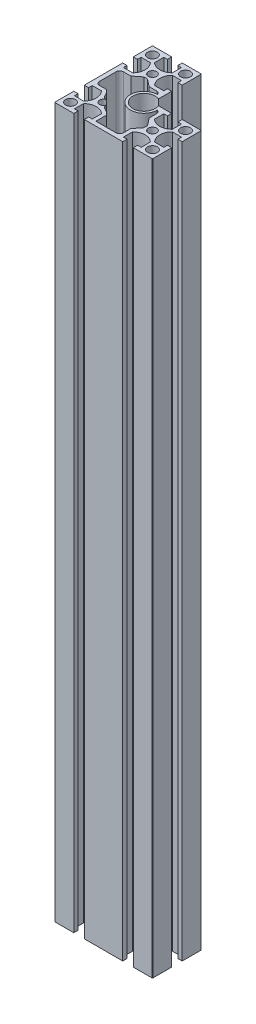
from build123d import *

# Parameters (mm, degrees)
SKETCH_2_R          = 4
SKETCH_2_R_2        = 3.4
EXTRUDE_1_DEPTH     = 580
SKETCH_3_R          = 5.341354258
SKETCH_3_R_2        = 5.383492222
SKETCH_3_R_3        = 4.933832051
SKETCH_3_R_4        = 5.418030405
SKETCH_3_R_5        = 5.574298651
EXTRUDE_2_DEPTH     = 580
SKETCH_4_R          = 4
CUT_EXTRUDE_1_DEPTH = 581


with BuildPart() as part:
    # 草图2 → 凸台-拉伸1 (new body)
    with BuildSketch(Plane(origin=(0, 0, 0), x_dir=(1, 0, 0), z_dir=(0, 1, 0))):
        with BuildLine():
            Line((212.330022346, 152.083698324), (201.421584322, 152.083698324))
            ThreePointArc((201.421584322, 152.083698324), (186.766061316, 142.219737293), (196.630022346, 156.8752603))
            Line((196.630022346, 156.8752603), (196.630022346, 167.783698324))
            Line((196.630022346, 167.783698324), (193.130022346, 167.783698324))
            Line((193.130022346, 167.783698324), (193.130022346, 164.833698324))
            Line((193.130022346, 164.833698324), (185.630022346, 164.833698324))
            ThreePointArc((185.630022346, 164.833698324), (182.630022346, 172.083698324), (185.630022346, 179.333698324))
            Line((185.630022346, 179.333698324), (193.130022346, 179.333698324))
            Line((193.130022346, 179.333698324), (193.130022346, 176.383698324))
            Line((193.130022346, 176.383698324), (196.630022346, 176.383698324))
            Line((196.630022346, 176.383698324), (196.630022346, 191.583698324))
            ThreePointArc((196.630022346, 191.583698324), (196.483575737, 191.937251715), (196.130022346, 192.083698324))
            Line((196.130022346, 192.083698324), (180.930022346, 192.083698324))
            Line((180.930022346, 192.083698324), (180.930022346, 188.583698324))
            Line((180.930022346, 188.583698324), (183.880022346, 188.583698324))
            Line((183.880022346, 188.583698324), (183.880022346, 181.083698324))
            ThreePointArc((183.880022346, 181.083698324), (176.630022346, 178.083698324), (169.380022346, 181.083698324))
            Line((169.380022346, 181.083698324), (169.380022346, 188.583698324))
            Line((169.380022346, 188.583698324), (172.330022346, 188.583698324))
            Line((172.330022346, 188.583698324), (172.330022346, 192.083698324))
            Line((172.330022346, 192.083698324), (157.130022346, 192.083698324))
            ThreePointArc((157.130022346, 192.083698324), (156.776468956, 191.937251715), (156.630022346, 191.583698324))
            Line((156.630022346, 191.583698324), (156.630022346, 176.383698324))
            Line((156.630022346, 176.383698324), (160.130022346, 176.383698324))
            Line((160.130022346, 176.383698324), (160.130022346, 179.333698324))
            Line((160.130022346, 179.333698324), (167.630022346, 179.333698324))
            ThreePointArc((167.630022346, 179.333698324), (170.630022346, 172.083698324), (167.630022346, 164.833698324))
            Line((167.630022346, 164.833698324), (160.130022346, 164.833698324))
            Line((160.130022346, 164.833698324), (160.130022346, 167.783698324))
            Line((160.130022346, 167.783698324), (156.630022346, 167.783698324))
            Line((156.630022346, 167.783698324), (156.630022346, 136.383698324))
            Line((156.630022346, 136.383698324), (160.130022346, 136.383698324))
            Line((160.130022346, 136.383698324), (160.130022346, 139.333698324))
            Line((160.130022346, 139.333698324), (167.630022346, 139.333698324))
            ThreePointArc((167.630022346, 139.333698324), (170.630022346, 132.083698324), (167.630022346, 124.833698324))
            Line((167.630022346, 124.833698324), (160.130022346, 124.833698324))
            Line((160.130022346, 124.833698324), (160.130022346, 127.783698324))
            Line((160.130022346, 127.783698324), (156.630022346, 127.783698324))
            Line((156.630022346, 127.783698324), (156.630022346, 112.583698324))
            ThreePointArc((156.630022346, 112.583698324), (156.776468956, 112.230144933), (157.130022346, 112.083698324))
            Line((157.130022346, 112.083698324), (172.330022346, 112.083698324))
            Line((172.330022346, 112.083698324), (172.330022346, 115.583698324))
            Line((172.330022346, 115.583698324), (169.380022346, 115.583698324))
            Line((169.380022346, 115.583698324), (169.380022346, 123.083698324))
            ThreePointArc((169.380022346, 123.083698324), (176.630022346, 126.083698324), (183.880022346, 123.083698324))
            Line((183.880022346, 123.083698324), (183.880022346, 115.583698324))
            Line((183.880022346, 115.583698324), (180.930022346, 115.583698324))
            Line((180.930022346, 115.583698324), (180.930022346, 112.083698324))
            Line((180.930022346, 112.083698324), (196.130022346, 112.083698324))
            Line((196.130022346, 112.083698324), (212.330022346, 112.083698324))
            Line((212.330022346, 112.083698324), (212.330022346, 115.583698324))
            Line((212.330022346, 115.583698324), (209.380022346, 115.583698324))
            Line((209.380022346, 115.583698324), (209.380022346, 123.083698324))
            ThreePointArc((209.380022346, 123.083698324), (216.630022346, 126.083698324), (223.880022346, 123.083698324))
            Line((223.880022346, 123.083698324), (223.880022346, 115.583698324))
            Line((223.880022346, 115.583698324), (220.930022346, 115.583698324))
            Line((220.930022346, 115.583698324), (220.930022346, 112.083698324))
            Line((220.930022346, 112.083698324), (236.130022346, 112.083698324))
            ThreePointArc((236.130022346, 112.083698324), (236.483575737, 112.230144933), (236.630022346, 112.583698324))
            Line((236.630022346, 112.583698324), (236.630022346, 127.783698324))
            Line((236.630022346, 127.783698324), (233.130022346, 127.783698324))
            Line((233.130022346, 127.783698324), (233.130022346, 124.833698324))
            Line((233.130022346, 124.833698324), (225.630022346, 124.833698324))
            ThreePointArc((225.630022346, 124.833698324), (222.630022346, 132.083698324), (225.630022346, 139.333698324))
            Line((225.630022346, 139.333698324), (233.130022346, 139.333698324))
            Line((233.130022346, 139.333698324), (233.130022346, 136.383698324))
            Line((233.130022346, 136.383698324), (236.630022346, 136.383698324))
            Line((236.630022346, 136.383698324), (236.630022346, 151.583698324))
            ThreePointArc((236.630022346, 151.583698324), (236.483575737, 151.937251715), (236.130022346, 152.083698324))
            Line((236.130022346, 152.083698324), (220.930022346, 152.083698324))
            Line((220.930022346, 152.083698324), (220.930022346, 148.583698324))
            Line((220.930022346, 148.583698324), (223.880022346, 148.583698324))
            Line((223.880022346, 148.583698324), (223.880022346, 141.083698324))
            ThreePointArc((223.880022346, 141.083698324), (216.630022346, 138.083698324), (209.380022346, 141.083698324))
            Line((209.380022346, 141.083698324), (209.380022346, 148.583698324))
            Line((209.380022346, 148.583698324), (212.330022346, 148.583698324))
            Line((212.330022346, 148.583698324), (212.330022346, 152.083698324))
        make_face()
        with Locations((162.630022346, 118.083698324)):
            Circle(SKETCH_2_R, mode=Mode.SUBTRACT)
        with BuildLine():
            ThreePointArc((206.380022346, 118.583698324), (205.50134269, 116.46237798), (203.380022346, 115.583698324))
            Line((203.380022346, 115.583698324), (186.880022346, 115.583698324))
            Line((186.880022346, 115.583698324), (186.880022346, 124.236137901))
            ThreePointArc((186.880022346, 124.236137901), (184.480651994, 126.510014755), (181.593404213, 128.119764513))
            ThreePointArc((181.593404213, 128.119764513), (180.080209042, 129.469558022), (179.77133004, 131.473627856))
            ThreePointArc((179.77133004, 131.473627856), (174.367280647, 129.820956624), (176.019951879, 135.225006017))
            ThreePointArc((176.019951879, 135.225006017), (174.015882044, 135.53388502), (172.666088535, 137.047080191))
            ThreePointArc((172.666088535, 137.047080191), (171.056338777, 139.934327972), (168.782461923, 142.333698324))
            Line((168.782461923, 142.333698324), (163.130022346, 142.333698324))
            ThreePointArc((163.130022346, 142.333698324), (161.008702003, 143.21237798), (160.130022346, 145.333698324))
            Line((160.130022346, 145.333698324), (160.130022346, 158.833698324))
            ThreePointArc((160.130022346, 158.833698324), (161.008702003, 160.955018668), (163.130022346, 161.833698324))
            Line((163.130022346, 161.833698324), (169.130022346, 161.833698324))
            Line((169.130022346, 161.833698324), (175.130022346, 166.583698324))
            Line((175.130022346, 166.583698324), (178.130022346, 166.583698324))
            Line((178.130022346, 166.583698324), (184.130022346, 161.833698324))
            Line((184.130022346, 161.833698324), (190.130022346, 161.833698324))
            ThreePointArc((190.130022346, 161.833698324), (191.967307675, 161.205276411), (193.034866096, 159.583286739))
            ThreePointArc((193.034866096, 159.583286739), (185.351847753, 140.805523731), (204.129610761, 148.488542073))
            ThreePointArc((204.129610761, 148.488542073), (205.751600433, 147.420983653), (206.380022346, 145.583698324))
            Line((206.380022346, 145.583698324), (206.380022346, 139.583698324))
            Line((206.380022346, 139.583698324), (211.130022346, 133.583698324))
            Line((211.130022346, 133.583698324), (211.130022346, 130.583698324))
            Line((211.130022346, 130.583698324), (206.380022346, 124.583698324))
            Line((206.380022346, 124.583698324), (206.380022346, 118.583698324))
        make_face(mode=Mode.SUBTRACT)
        with Locations((230.630022346, 118.083698324)):
            Circle(SKETCH_2_R, mode=Mode.SUBTRACT)
        with Locations((216.630022346, 132.083698324)):
            Circle(SKETCH_2_R_2, mode=Mode.SUBTRACT)
        with Locations((230.130022346, 145.583698324)):
            Circle(SKETCH_2_R, mode=Mode.SUBTRACT)
        with Locations((176.630022346, 172.083698324)):
            Circle(SKETCH_2_R_2, mode=Mode.SUBTRACT)
        with Locations((163.130022346, 186.083698324)):
            Circle(SKETCH_2_R, mode=Mode.SUBTRACT)
        with Locations((190.130022346, 185.583698324)):
            Circle(SKETCH_2_R, mode=Mode.SUBTRACT)
    extrude(amount=EXTRUDE_1_DEPTH)

    # 草图3 → 凸台-拉伸2 (add)
    with BuildSketch(Plane(origin=(0, 580, 0), x_dir=(1, 0, 0), z_dir=(0, 1, 0))):
        with Locations((163.130022346, 186.083698324)):
            Circle(SKETCH_3_R)
        with Locations((190.130022346, 185.583698324)):
            Circle(SKETCH_3_R_2)
        with Locations((162.630022346, 118.083698324)):
            Circle(SKETCH_3_R_3)
        with Locations((230.630022346, 118.083698324)):
            Circle(SKETCH_3_R_4)
        with Locations((230.130022346, 145.583698324)):
            Circle(SKETCH_3_R_5)
    extrude(amount=-EXTRUDE_2_DEPTH)

    # 草图4 → 切除-拉伸1 (cut, through all)
    with BuildSketch(Plane(origin=(0, 580, 0), x_dir=(1, 0, 0), z_dir=(0, 1, 0))):
        with Locations((163.130022346, 185.583698324)):
            Circle(SKETCH_4_R)
        with Locations((163.130022346, 118.583698324)):
            Circle(SKETCH_4_R)
        with Locations((230.130022346, 118.583698324)):
            Circle(SKETCH_4_R)
        with Locations((230.130022346, 145.583698324)):
            Circle(SKETCH_4_R)
        with Locations((190.130022346, 185.583698324)):
            Circle(SKETCH_4_R)
    extrude(amount=-CUT_EXTRUDE_1_DEPTH, mode=Mode.SUBTRACT)


solid = part.part
